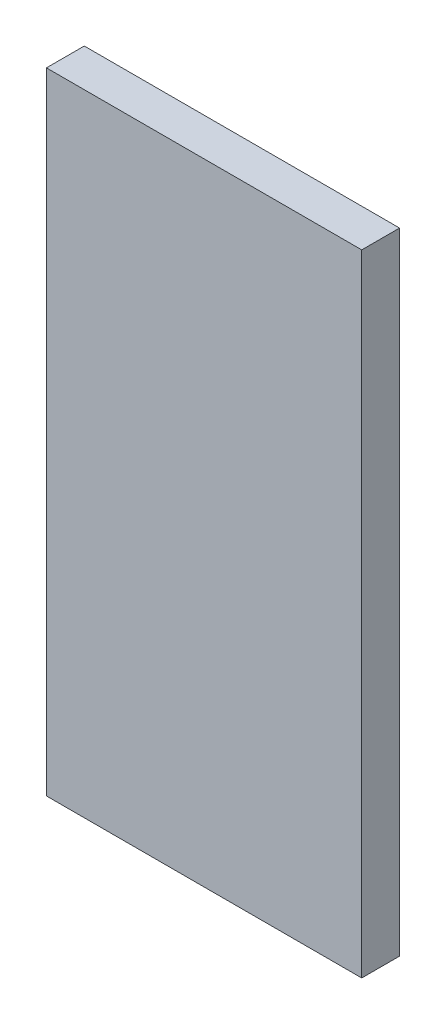
from build123d import *

# Parameters (mm, degrees)
CROQUIS1_W              = 100
CROQUIS1_H              = 200
SALIENTE_EXTRUIR1_DEPTH = 12


with BuildPart() as part:
    # Croquis1 → Saliente-Extruir1 (new body)
    with BuildSketch(Plane.XY):
        Rectangle(CROQUIS1_W, CROQUIS1_H)
    extrude(amount=SALIENTE_EXTRUIR1_DEPTH)


solid = part.part
